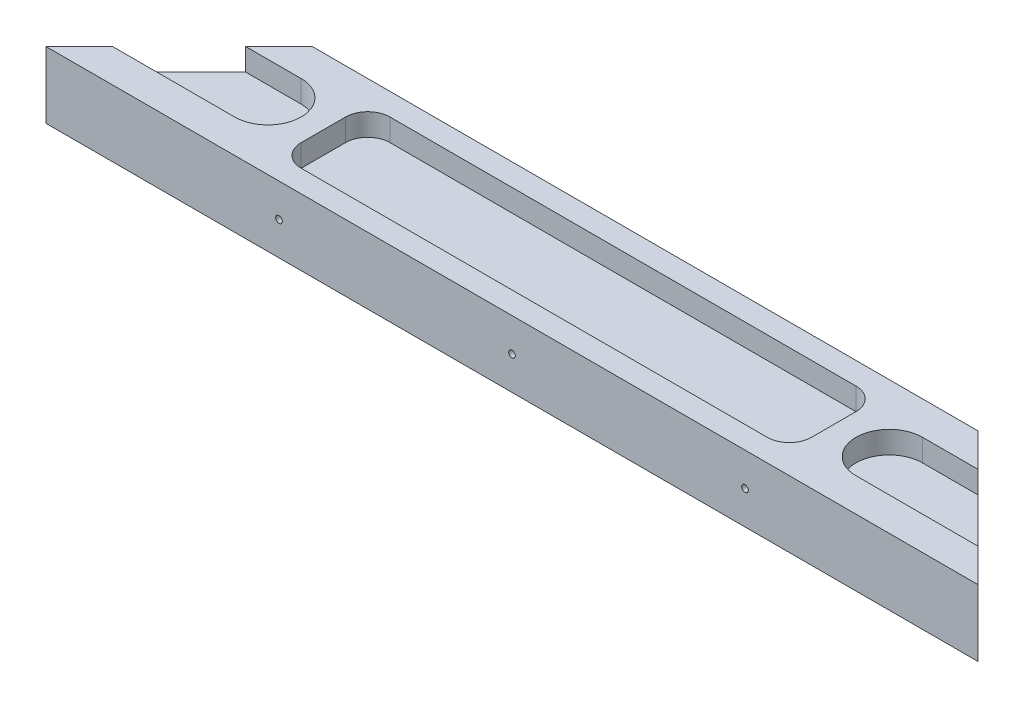
from build123d import *

# Parameters (mm, degrees)
BOSS_EXTRUDE1_DEPTH = 15
CUT_EXTRUDE1_DEPTH  = 5
SKETCH3_R           = 0.75
CUT_EXTRUDE2_DEPTH  = 30
CUT_EXTRUDE3_DEPTH  = 5


with BuildPart() as part:
    # Sketch1 → Boss-Extrude1 (new body)
    with BuildSketch(Plane(origin=(0, 0, 0), x_dir=(1, 0, 0), z_dir=(0, 1, 0))):
        Polygon((0, 0), (210, 0), (180, 30), (30, 30), align=None)
    extrude(amount=BOSS_EXTRUDE1_DEPTH)

    # Sketch2 → Cut-Extrude1 (cut)
    with BuildSketch(Plane(origin=(0, 15, 0), x_dir=(1, 0, 0), z_dir=(0, 1, 0))):
        with BuildLine():
            Line((-5, 22.5), (35, 22.5))
            ThreePointArc((35, 22.5), (42.5, 15), (35, 7.5))
            Line((35, 7.5), (-5, 7.5))
            ThreePointArc((-5, 7.5), (-12.5, 15), (-5, 22.5))
        make_face()
        with BuildLine():
            Line((215, 22.5), (175, 22.5))
            ThreePointArc((175, 22.5), (167.5, 15), (175, 7.5))
            Line((175, 7.5), (215, 7.5))
            ThreePointArc((215, 7.5), (222.5, 15), (215, 22.5))
        make_face()
    extrude(amount=-CUT_EXTRUDE1_DEPTH, mode=Mode.SUBTRACT)

    # Sketch3 → Cut-Extrude2 (cut)
    with BuildSketch(Plane.XY):
        with Locations((105, 7.5)):
            Circle(SKETCH3_R)
        with Locations((52.5, 7.5)):
            Circle(SKETCH3_R)
        with Locations((157.5, 7.5)):
            Circle(SKETCH3_R)
    extrude(amount=-CUT_EXTRUDE2_DEPTH, mode=Mode.SUBTRACT)

    # Sketch4 → Cut-Extrude3 (cut)
    with BuildSketch(Plane(origin=(0, 15, 0), x_dir=(1, 0, 0), z_dir=(0, 1, 0))):
        with BuildLine():
            Line((52.5, 25), (157.5, 25))
            ThreePointArc((157.5, 25), (161.035533906, 23.535533906), (162.5, 20))
            Line((162.5, 20), (162.5, 10))
            ThreePointArc((162.5, 10), (161.035533906, 6.464466094), (157.5, 5))
            Line((157.5, 5), (52.5, 5))
            ThreePointArc((52.5, 5), (48.964466094, 6.464466094), (47.5, 10))
            Line((47.5, 10), (47.5, 20))
            ThreePointArc((47.5, 20), (48.964466094, 23.535533906), (52.5, 25))
        make_face()
    extrude(amount=-CUT_EXTRUDE3_DEPTH, mode=Mode.SUBTRACT)


solid = part.part
